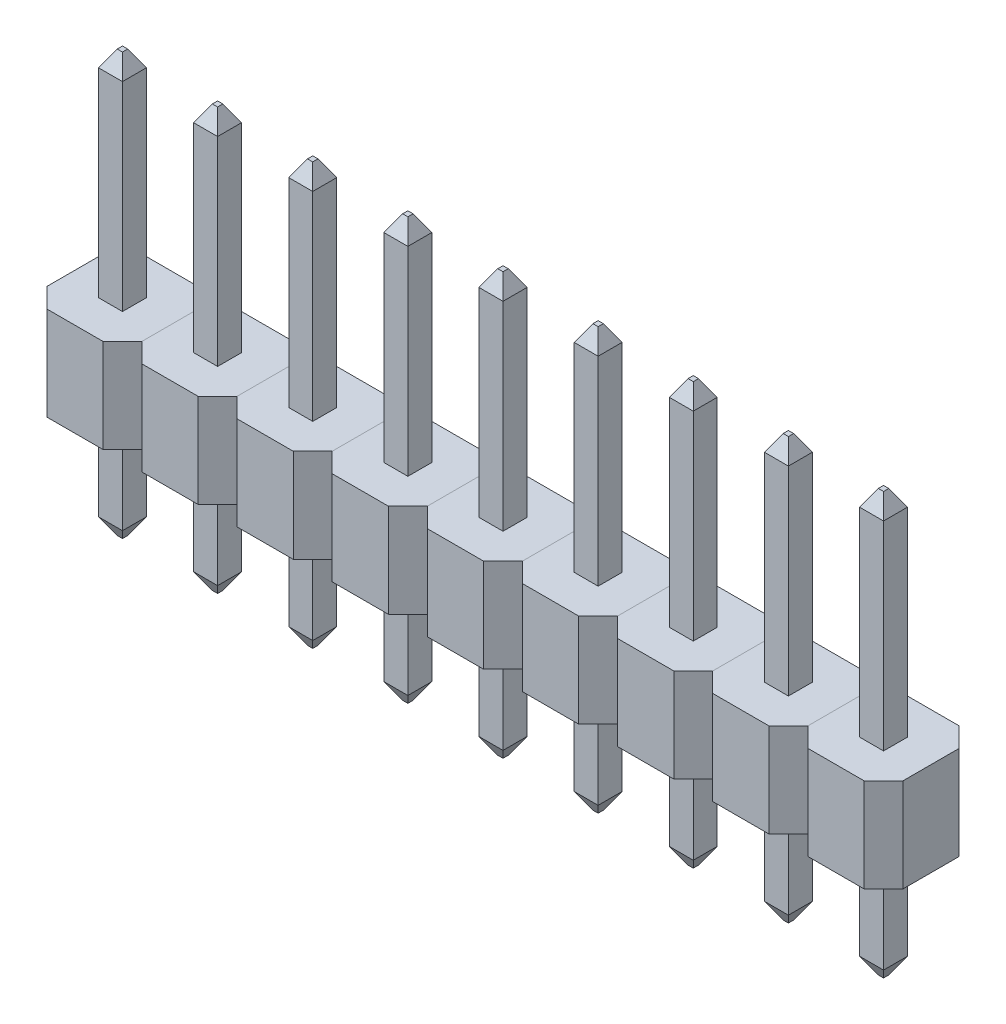
from build123d import *

# Parameters (mm, degrees)
SKETCH1_W                     = 2.54
SKETCH1_H                     = 2.54
SKETCH1_W_2                   = 0.64
SKETCH1_H_2                   = 0.64
PLASTIC_CONNECTION_BODY_DEPTH = 2.5
CORNERS_TRIMMED_DEPTH         = 2.5
SKETCH4_W                     = 0.64
SKETCH4_H                     = 0.64
METAL_PIN_DEPTH               = 3
METAL_PIN_DEPTH_BACK          = 8.25
METAL_PIN_CHAMFER_1_SIZE      = 0.25
METAL_PIN_CHAMFER_1_SIZE2     = 0.433012702
METAL_PIN_CHAMFER_2_SIZE      = 0.25
METAL_PIN_CHAMFER_2_SIZE2     = 0.433012702
SKETCH5_R                     = 0.5
CUT_EXTRUDE1_DEPTH            = 0.1
LPATTERN_1_COUNT              = 5
LPATTERN_1_PITCH              = 2.54
LPATTERN_1_2_COUNT            = 5
LPATTERN_1_2_PITCH            = 2.54


with BuildPart() as part:
    # Sketch1 → Plastic Connection Body (new body)
    with BuildSketch(Plane(origin=(0, 0, 0), x_dir=(1, 0, 0), z_dir=(0, 1, 0))):
        Rectangle(SKETCH1_W, SKETCH1_H)
        Rectangle(SKETCH1_W_2, SKETCH1_H_2, mode=Mode.SUBTRACT)
    extrude(amount=PLASTIC_CONNECTION_BODY_DEPTH)

    # Sketch3 → Corners Trimmed (cut)
    with BuildSketch(Plane(origin=(0, 2.5, 0), x_dir=(1, 0, 0), z_dir=(0, 1, 0))):
        Polygon((-0.75, 1.27), (-1.27, 0.75), (-1.27, 1.27), align=None)
        Polygon((0.75, 1.27), (1.27, 0.75), (1.27, 1.27), align=None)
        Polygon((-1.27, -0.75), (-1.27, -1.27), (-0.75, -1.27), align=None)
        Polygon((0.75, -1.27), (1.27, -0.75), (1.27, -1.27), align=None)
    extrude(amount=-CORNERS_TRIMMED_DEPTH, mode=Mode.SUBTRACT)

    # Sketch5 → Cut-Extrude1 (cut)
    with BuildSketch(Plane.XZ):
        Circle(SKETCH5_R)
    extrude(amount=-CUT_EXTRUDE1_DEPTH, mode=Mode.SUBTRACT)


with BuildPart() as body_2:
    # Sketch4 → Metal Pin (new body, two sides)
    with BuildSketch(Plane.XZ) as metal_pin_sk:
        Rectangle(SKETCH4_W, SKETCH4_H)
    extrude(amount=METAL_PIN_DEPTH)
    extrude(metal_pin_sk.sketch, amount=-METAL_PIN_DEPTH_BACK)

    # Metal Pin Chamfer-1
    metal_pin_chamfer_1_edges = [body_2.edges().sort_by_distance(p)[0] for p in [
        (0, -3, -0.32),
        (0.32, -3, 0),
        (0, -3, 0.32),
        (-0.32, -3, 0),
    ]]
    metal_pin_chamfer_1_side = [body_2.faces().sort_by_distance(p)[0] for p in [
        (0, -3, 0),
    ]]
    chamfer(metal_pin_chamfer_1_edges, length=METAL_PIN_CHAMFER_1_SIZE, length2=METAL_PIN_CHAMFER_1_SIZE2, reference=metal_pin_chamfer_1_side[0])

    # Metal Pin Chamfer-2
    metal_pin_chamfer_2_edges = [body_2.edges().sort_by_distance(p)[0] for p in [
        (0, 8.25, 0.32),
        (-0.32, 8.25, 0),
        (0, 8.25, -0.32),
        (0.32, 8.25, 0),
    ]]
    metal_pin_chamfer_2_side = [body_2.faces().sort_by_distance(p)[0] for p in [
        (0, 8.25, 0),
    ]]
    chamfer(metal_pin_chamfer_2_edges, length=METAL_PIN_CHAMFER_2_SIZE, length2=METAL_PIN_CHAMFER_2_SIZE2, reference=metal_pin_chamfer_2_side[0])


with BuildPart() as lpattern_1_1:
    # LPattern-1: pattern copy
    add(part.part.moved(Location(Vector(1, 0, 0) * (1 * LPATTERN_1_PITCH))))


with BuildPart() as lpattern_1_2:
    # LPattern-1: pattern copy
    add(part.part.moved(Location(Vector(1, 0, 0) * (2 * LPATTERN_1_PITCH))))


with BuildPart() as lpattern_1_3:
    # LPattern-1: pattern copy
    add(part.part.moved(Location(Vector(1, 0, 0) * (3 * LPATTERN_1_PITCH))))


with BuildPart() as lpattern_1_4:
    # LPattern-1: pattern copy
    add(part.part.moved(Location(Vector(1, 0, 0) * (4 * LPATTERN_1_PITCH))))


with BuildPart() as lpattern_1_5:
    # LPattern-1: pattern copy
    add(body_2.part.moved(Location(Vector(1, 0, 0) * (1 * LPATTERN_1_PITCH))))


with BuildPart() as lpattern_1_6:
    # LPattern-1: pattern copy
    add(body_2.part.moved(Location(Vector(1, 0, 0) * (2 * LPATTERN_1_PITCH))))


with BuildPart() as lpattern_1_7:
    # LPattern-1: pattern copy
    add(body_2.part.moved(Location(Vector(1, 0, 0) * (3 * LPATTERN_1_PITCH))))


with BuildPart() as lpattern_1_8:
    # LPattern-1: pattern copy
    add(body_2.part.moved(Location(Vector(1, 0, 0) * (4 * LPATTERN_1_PITCH))))


with BuildPart() as lpattern_1_2_1:
    # LPattern-1 2: pattern copy
    add(part.part.moved(Location(Vector(-1, 0, 0) * (1 * LPATTERN_1_2_PITCH))))


with BuildPart() as lpattern_1_2_2:
    # LPattern-1 2: pattern copy
    add(part.part.moved(Location(Vector(-1, 0, 0) * (2 * LPATTERN_1_2_PITCH))))


with BuildPart() as lpattern_1_2_3:
    # LPattern-1 2: pattern copy
    add(part.part.moved(Location(Vector(-1, 0, 0) * (3 * LPATTERN_1_2_PITCH))))


with BuildPart() as lpattern_1_2_4:
    # LPattern-1 2: pattern copy
    add(part.part.moved(Location(Vector(-1, 0, 0) * (4 * LPATTERN_1_2_PITCH))))


with BuildPart() as lpattern_1_2_5:
    # LPattern-1 2: pattern copy
    add(body_2.part.moved(Location(Vector(-1, 0, 0) * (1 * LPATTERN_1_2_PITCH))))


with BuildPart() as lpattern_1_2_6:
    # LPattern-1 2: pattern copy
    add(body_2.part.moved(Location(Vector(-1, 0, 0) * (2 * LPATTERN_1_2_PITCH))))


with BuildPart() as lpattern_1_2_7:
    # LPattern-1 2: pattern copy
    add(body_2.part.moved(Location(Vector(-1, 0, 0) * (3 * LPATTERN_1_2_PITCH))))


with BuildPart() as lpattern_1_2_8:
    # LPattern-1 2: pattern copy
    add(body_2.part.moved(Location(Vector(-1, 0, 0) * (4 * LPATTERN_1_2_PITCH))))


solid = Compound([part.part, body_2.part, lpattern_1_1.part, lpattern_1_2.part, lpattern_1_3.part, lpattern_1_4.part, lpattern_1_5.part, lpattern_1_6.part, lpattern_1_7.part, lpattern_1_8.part, lpattern_1_2_1.part, lpattern_1_2_2.part, lpattern_1_2_3.part, lpattern_1_2_4.part, lpattern_1_2_5.part, lpattern_1_2_6.part, lpattern_1_2_7.part, lpattern_1_2_8.part])
